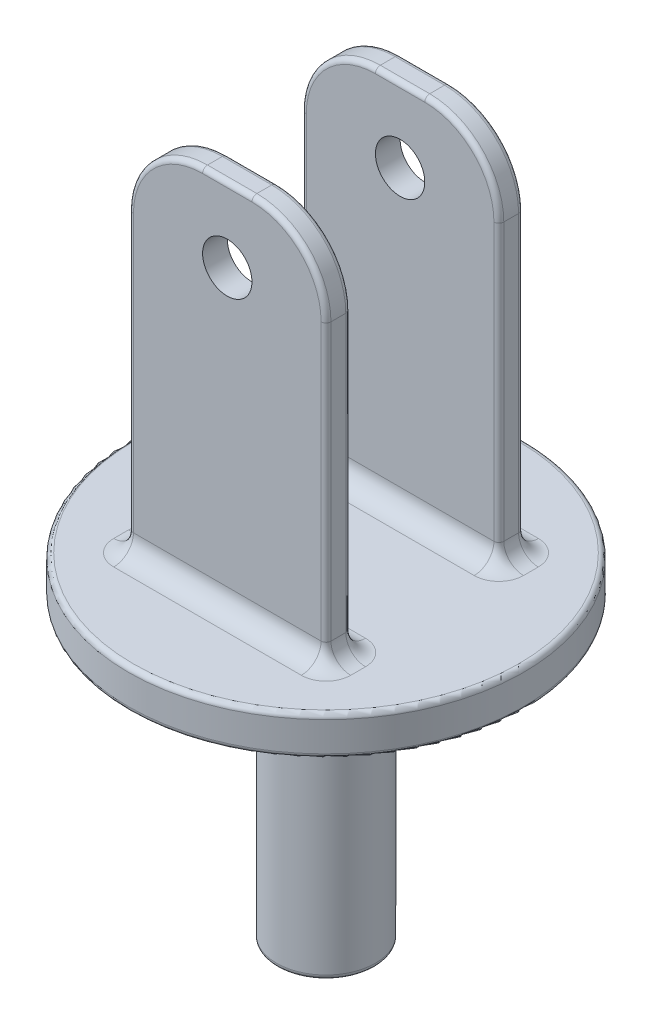
from build123d import *

# Parameters (mm, degrees)
SKETCH1_R            = 40
BOSS_EXTRUDE1_DEPTH  = 8
BOSS_EXTRUDE4_DEPTH  = 75
FILLET4_R            = 15
FILLET6_R            = 1
FILLET8_R            = 1
FILLET9_R            = 4
FILLET4_OF_MIRROR6_R = 15
FILLET6_OF_MIRROR6_R = 1
FILLET8_OF_MIRROR6_R = 1
FILLET9_OF_MIRROR6_R = 4
CUT_EXTRUDE1_DEPTH   = 76
SKETCH5_R            = 10
SKETCH5_R_2          = 7.5
BOSS_EXTRUDE5_DEPTH  = 60
FILLET10_R           = 1
FILLET11_R           = 1


with BuildPart() as part:
    # Sketch1 → Boss-Extrude1 (new body)
    with BuildSketch(Plane(origin=(0, 0, 0), x_dir=(1, 0, 0), z_dir=(0, 1, 0))):
        Circle(SKETCH1_R)
    extrude(amount=BOSS_EXTRUDE1_DEPTH)

    # Sketch2 → Boss-Extrude4 (add)
    with BuildSketch(Plane(origin=(0, 8, 0), x_dir=(1, 0, 0), z_dir=(0, 1, 0))):
        Polygon((20, 20), (0, 17.5), (20, 15), align=None)
        Polygon((-20, 20), (0, 17.5), (20, 20), align=None)
        Polygon((0, 17.5), (0, 15), (20, 15), align=None)
        Polygon((-20, 15), (0, 15), (0, 17.5), align=None)
        Polygon((-20, 15), (0, 17.5), (-20, 20), align=None)
    boss_extrude4 = extrude(amount=BOSS_EXTRUDE4_DEPTH)

    # Fillet4
    fillet4_edges = [part.edges().sort_by_distance(p)[0] for p in [
        (20, 83, -17.5),
        (-20, 83, -17.5),
    ]]
    fillet(fillet4_edges, radius=FILLET4_R)

    # Fillet6
    fillet6_edges = [part.edges().sort_by_distance(p)[0] for p in [
        (20, 38, -15),
        (0, 83, -15),
        (-20, 38, -15),
        (-15.606601718, 78.606601718, -15),
        (15.606601718, 78.606601718, -15),
    ]]
    fillet(fillet6_edges, radius=FILLET6_R)

    # Fillet8
    fillet8_edges = [part.edges().sort_by_distance(p)[0] for p in [
        (20, 38, -20),
        (0, 83, -20),
        (-20, 38, -20),
        (-15.606601718, 78.606601718, -20),
        (15.606601718, 78.606601718, -20),
    ]]
    fillet(fillet8_edges, radius=FILLET8_R)

    # Fillet9
    fillet9_edges = [part.edges().sort_by_distance(p)[0] for p in [
        (0, 8, -15),
        (19.707106781, 8, -15.292893219),
        (-19.707106781, 8, -15.292893219),
        (-20, 8, -17.5),
        (0, 8, -20),
        (20, 8, -17.5),
        (-19.707106781, 8, -19.707106781),
        (19.707106781, 8, -19.707106781),
    ]]
    fillet(fillet9_edges, radius=FILLET9_R)

    # Mirror6: Boss-Extrude4 across plane
    add(boss_extrude4.mirror(Plane.XY))

    # Fillet4 of Mirror6
    fillet4_of_mirror6_edges = [part.edges().sort_by_distance(p)[0] for p in [
        (20, 83, 17.5),
        (-20, 83, 17.5),
    ]]
    fillet(fillet4_of_mirror6_edges, radius=FILLET4_OF_MIRROR6_R)

    # Fillet6 of Mirror6
    fillet6_of_mirror6_edges = [part.edges().sort_by_distance(p)[0] for p in [
        (20, 38, 15),
        (0, 83, 15),
        (-20, 38, 15),
        (-15.606601718, 78.606601718, 15),
        (15.606601718, 78.606601718, 15),
    ]]
    fillet(fillet6_of_mirror6_edges, radius=FILLET6_OF_MIRROR6_R)

    # Fillet8 of Mirror6
    fillet8_of_mirror6_edges = [part.edges().sort_by_distance(p)[0] for p in [
        (20, 38, 20),
        (0, 83, 20),
        (-20, 38, 20),
        (-15.606601718, 78.606601718, 20),
        (15.606601718, 78.606601718, 20),
    ]]
    fillet(fillet8_of_mirror6_edges, radius=FILLET8_OF_MIRROR6_R)

    # Fillet9 of Mirror6
    fillet9_of_mirror6_edges = [part.edges().sort_by_distance(p)[0] for p in [
        (0, 8, 15),
        (19.707106781, 8, 15.292893219),
        (-19.707106781, 8, 15.292893219),
        (-20, 8, 17.5),
        (0, 8, 20),
        (20, 8, 17.5),
        (-19.707106781, 8, 19.707106781),
        (19.707106781, 8, 19.707106781),
    ]]
    fillet(fillet9_of_mirror6_edges, radius=FILLET9_OF_MIRROR6_R)

    # Sketch3 → Cut-Extrude1 (cut)
    with BuildSketch(Plane(origin=(0, 0, -20), x_dir=(-1, 0, 0), z_dir=(0, 0, -1))):
        with BuildLine():
            ThreePointArc((5, 68), (3.535533906, 71.535533906), (0, 73))
            Line((0, 73), (0, 63))
            ThreePointArc((0, 63), (3.535533906, 64.464466094), (5, 68))
        make_face()
        with BuildLine():
            Line((0, 63), (0, 73))
            ThreePointArc((0, 73), (-5, 68), (0, 63))
        make_face()
    extrude(amount=-CUT_EXTRUDE1_DEPTH, mode=Mode.SUBTRACT)

    # Sketch5 → Boss-Extrude5 (add)
    with BuildSketch(Plane.XZ):
        Circle(SKETCH5_R)
        Circle(SKETCH5_R_2, mode=Mode.SUBTRACT)
    extrude(amount=BOSS_EXTRUDE5_DEPTH)

    # Fillet10
    fillet10_edges = [part.edges().sort_by_distance(p)[0] for p in [
        (-10, -60, 0),
    ]]
    fillet(fillet10_edges, radius=FILLET10_R)

    # Fillet11
    fillet11_edges = [part.edges().sort_by_distance(p)[0] for p in [
        (-40, 0, 0),
        (-40, 8, 0),
    ]]
    fillet(fillet11_edges, radius=FILLET11_R)


solid = part.part
